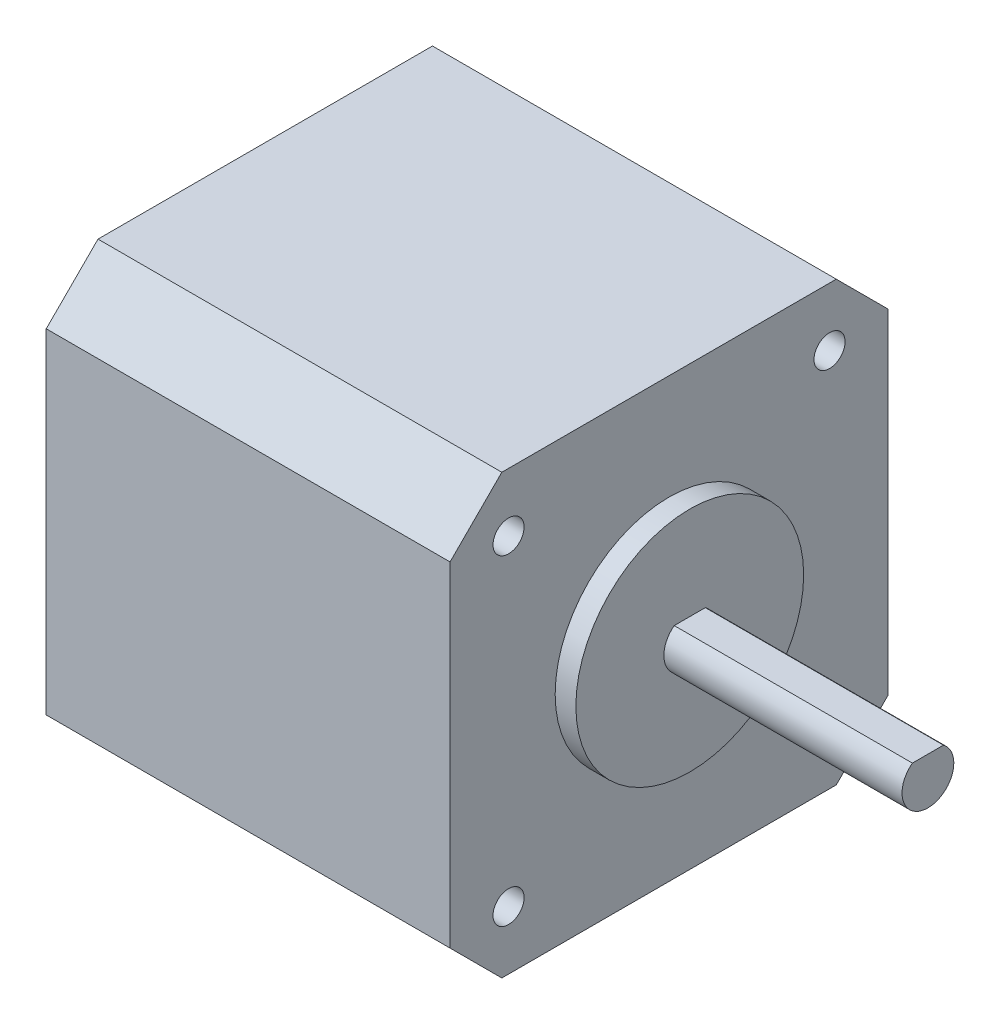
from build123d import *

# Parameters (mm, degrees)
SKETCH1_R           = 1.5
BOSS_EXTRUDE1_DEPTH = 39
SKETCH2_R           = 11
BOSS_EXTRUDE2_DEPTH = 2
BOSS_EXTRUDE3_DEPTH = 23


with BuildPart() as part:
    # Sketch1 → Boss-Extrude1 (new body)
    with BuildSketch(Plane(origin=(0, 0, 0), x_dir=(0, 0, -1), z_dir=(1, 0, 0))):
        Polygon((0, 37.3), (5, 42.3), (37.3, 42.3), (42.3, 37.3), (42.3, 5), (37.3, 0), (5, 0), (0, 5), align=None)
        with Locations((5.65, 36.65)):
            Circle(SKETCH1_R, mode=Mode.SUBTRACT)
        with Locations((36.65, 36.65)):
            Circle(SKETCH1_R, mode=Mode.SUBTRACT)
        with Locations((36.65, 5.65)):
            Circle(SKETCH1_R, mode=Mode.SUBTRACT)
        with Locations((5.65, 5.65)):
            Circle(SKETCH1_R, mode=Mode.SUBTRACT)
    extrude(amount=BOSS_EXTRUDE1_DEPTH)

    # Sketch2 → Boss-Extrude2 (add)
    with BuildSketch(Plane(origin=(39, 0, 0), x_dir=(0, 0, -1), z_dir=(1, 0, 0))):
        with Locations((21.15, 21.15)):
            Circle(SKETCH2_R)
    extrude(amount=BOSS_EXTRUDE2_DEPTH)

    # Sketch3 → Boss-Extrude3 (add)
    with BuildSketch(Plane(origin=(41, 0, 0), x_dir=(0, 0, -1), z_dir=(1, 0, 0))):
        with BuildLine():
            Line((19.65, 23.15), (22.65, 23.15))
            ThreePointArc((22.65, 23.15), (21.15, 18.65), (19.65, 23.15))
        make_face()
    extrude(amount=BOSS_EXTRUDE3_DEPTH)


solid = part.part
